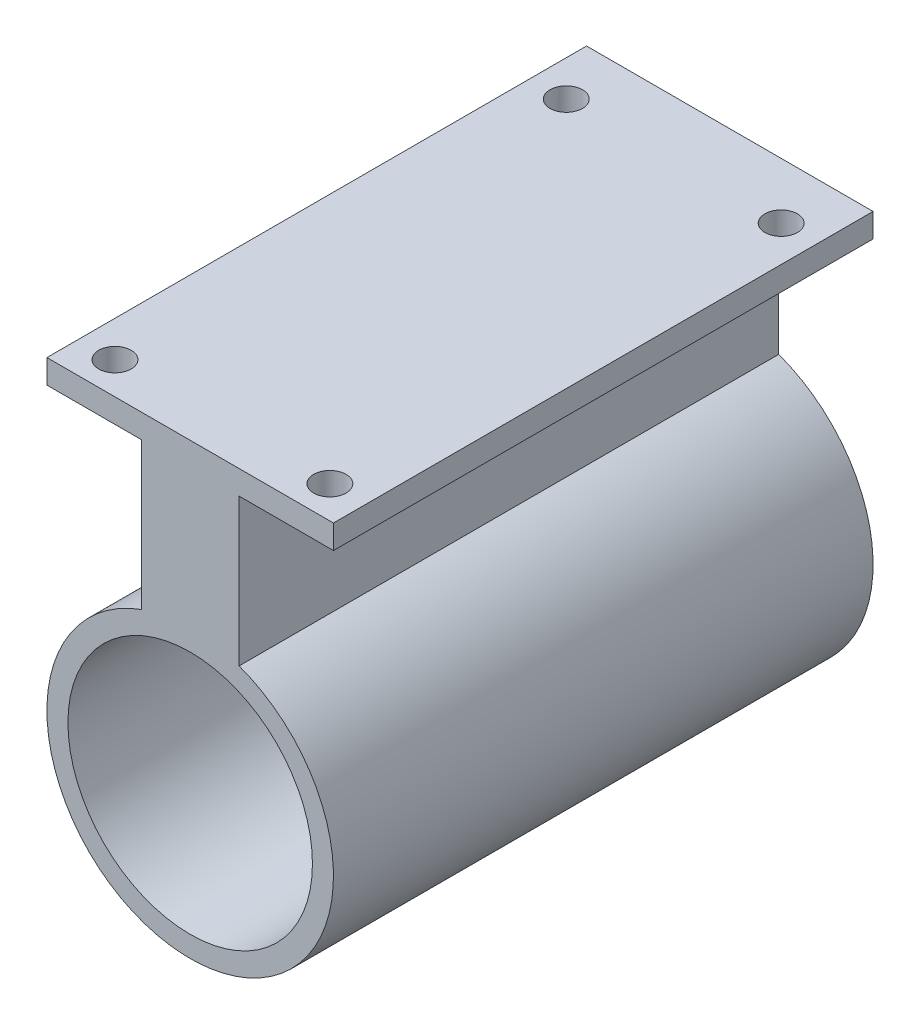
from build123d import *

# Parameters (mm, degrees)
CROQUIS1_R              = 12.5
SALIENTE_EXTRUIR1_DEPTH = 54
CROQUIS2_R              = 15
SALIENTE_EXTRUIR2_DEPTH = 2.5
CROQUIS3_R              = 3.75
CORTAR_EXTRUIR2_DEPTH   = 2.5
CROQUIS5_R              = 1.5
CORTAR_EXTRUIR3_DEPTH   = 2.5
CROQUIS9_R              = 1.5
CORTAR_EXTRUIR5_DEPTH   = 2.5
SALIENTE_EXTRUIR3_DEPTH = 2.5
CROQUIS11_R             = 12.8
CORTAR_EXTRUIR6_DEPTH   = 54
CROQUIS12_R             = 1.7
CORTAR_EXTRUIR7_DEPTH   = 2.5
CROQUIS16_R             = 1.7
CORTAR_EXTRUIR8_DEPTH   = 2.5
CROQUIS17_R             = 1.7
CORTAR_EXTRUIR9_DEPTH   = 2.5


with BuildPart() as part:
    # Croquis1 → Saliente-Extruir1 (new body)
    with BuildSketch(Plane.XY):
        with BuildLine():
            Line((-5.119897429, -1.25), (-15, -1.25))
            Line((-15, -1.25), (-15, 1.25))
            Line((-15, 1.25), (15, 1.25))
            Line((15, 1.25), (15, -1.25))
            Line((15, -1.25), (5.119897429, -1.25))
            Line((5.119897429, -1.25), (5.119897429, -13.25))
            Line((5.119897429, -13.25), (5.119897429, -16.650828027))
            ThreePointArc((5.119897429, -16.650828027), (0, -45.75), (-5.119897429, -16.650828027))
            Line((-5.119897429, -16.650828027), (-5.119897429, -13.25))
            Line((-5.119897429, -13.25), (-5.119897429, -1.25))
        make_face()
        with Locations((0, -30.75)):
            Circle(CROQUIS1_R, mode=Mode.SUBTRACT)
    extrude(amount=SALIENTE_EXTRUIR1_DEPTH)

    # Croquis2 → Saliente-Extruir2 (add)
    with BuildSketch(Plane(origin=(0, 0, 0), x_dir=(-1, 0, 0), z_dir=(0, 0, -1))):
        with Locations((0, -30.75)):
            Circle(CROQUIS2_R)
    extrude(amount=SALIENTE_EXTRUIR2_DEPTH)

    # Croquis3 → Cortar-Extruir2 (cut)
    with BuildSketch(Plane(origin=(0, 0, -2.5), x_dir=(-1, 0, 0), z_dir=(0, 0, -1))):
        with Locations((0, -30.75)):
            Circle(CROQUIS3_R)
    extrude(amount=-CORTAR_EXTRUIR2_DEPTH, mode=Mode.SUBTRACT)

    # Croquis5 → Cortar-Extruir3 (cut)
    with BuildSketch(Plane(origin=(0, 0, -2.5), x_dir=(-1, 0, 0), z_dir=(0, 0, -1))):
        with Locations((0, -22.25)):
            Circle(CROQUIS5_R)
        with Locations((0, -39.25)):
            Circle(CROQUIS5_R)
    extrude(amount=-CORTAR_EXTRUIR3_DEPTH, mode=Mode.SUBTRACT)

    # Croquis9 → Cortar-Extruir5 (cut)
    with BuildSketch(Plane(origin=(0, 1.25, 0), x_dir=(1, 0, 0), z_dir=(0, 1, 0))):
        with Locations((-11.25, -50.625)):
            Circle(CROQUIS9_R)
        with Locations((-11.25, -3.375)):
            Circle(CROQUIS9_R)
        with Locations((11.25, -50.625)):
            Circle(CROQUIS9_R)
        with Locations((11.25, -3.375)):
            Circle(CROQUIS9_R)
    extrude(amount=-CORTAR_EXTRUIR5_DEPTH, mode=Mode.SUBTRACT)

    # Croquis10 → Saliente-Extruir3 (add)
    with BuildSketch(Plane(origin=(0, 0, 0), x_dir=(-1, 0, 0), z_dir=(0, 0, -1))):
        with BuildLine():
            Line((-15, 1.25), (15, 1.25))
            Line((15, 1.25), (15, -1.25))
            Line((15, -1.25), (5.119897429, -1.25))
            Line((5.119897429, -1.25), (5.119897429, -16.650828027))
            ThreePointArc((5.119897429, -16.650828027), (0, -15.75), (-5.119897429, -16.650828027))
            Line((-5.119897429, -16.650828027), (-5.119897429, -1.25))
            Line((-5.119897429, -1.25), (-15, -1.25))
            Line((-15, -1.25), (-15, 1.25))
        make_face()
    extrude(amount=SALIENTE_EXTRUIR3_DEPTH)

    # Croquis11 → Cortar-Extruir6 (cut)
    with BuildSketch(Plane.XY.offset(54)):
        with Locations((0, -30.75)):
            Circle(CROQUIS11_R)
    extrude(amount=-CORTAR_EXTRUIR6_DEPTH, mode=Mode.SUBTRACT)

    # Croquis12 → Cortar-Extruir7 (cut)
    with BuildSketch(Plane(origin=(0, 0, -2.5), x_dir=(-1, 0, 0), z_dir=(0, 0, -1))):
        with Locations((0, -22.25)):
            Circle(CROQUIS12_R)
        with Locations((0, -39.25)):
            Circle(CROQUIS12_R)
    extrude(amount=-CORTAR_EXTRUIR7_DEPTH, mode=Mode.SUBTRACT)

    # Croquis16 → Cortar-Extruir8 (cut)
    with BuildSketch(Plane(origin=(0, 1.25, 0), x_dir=(1, 0, 0), z_dir=(0, 1, 0))):
        with Locations((-11.25, -3.375)):
            Circle(CROQUIS16_R)
    extrude(amount=-CORTAR_EXTRUIR8_DEPTH, mode=Mode.SUBTRACT)

    # Croquis17 → Cortar-Extruir9 (cut)
    with BuildSketch(Plane(origin=(0, 1.25, 0), x_dir=(1, 0, 0), z_dir=(0, 1, 0))):
        with Locations((-11.25, -3.375)):
            Circle(CROQUIS17_R)
        with Locations((11.25, -3.375)):
            Circle(CROQUIS17_R)
        with Locations((-11.25, -50.625)):
            Circle(CROQUIS17_R)
        with Locations((11.25, -50.625)):
            Circle(CROQUIS17_R)
    extrude(amount=-CORTAR_EXTRUIR9_DEPTH, mode=Mode.SUBTRACT)


solid = part.part
